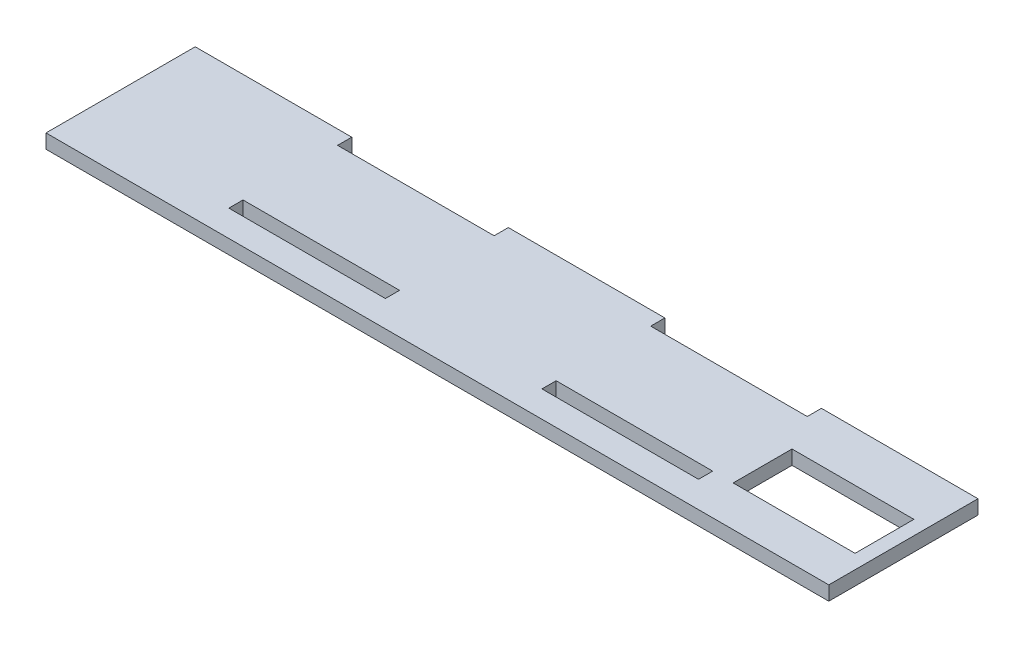
from build123d import *

# Parameters (mm, degrees)
SKETCH1_W           = 29.8
SKETCH1_H           = 2.7
SKETCH1_W_2         = 23.2
SKETCH1_H_2         = 11.2
BOSS_EXTRUDE1_DEPTH = 2.7


with BuildPart() as part:
    # Sketch1 → Boss-Extrude1 (new body)
    with BuildSketch(Plane(origin=(0, 0, 0), x_dir=(1, 0, 0), z_dir=(0, 1, 0))):
        Polygon((-74.5, -14.2), (74.5, -14.2), (74.5, 14.2), (44.7, 14.2), (44.7, 11.5), (14.9, 11.5), (14.9, 14.2), (-14.9, 14.2), (-14.9, 11.5), (-44.7, 11.5), (-44.7, 14.2), (-74.5, 14.2), align=None)
        with Locations((-29.8, -7.85)):
            Rectangle(SKETCH1_W, SKETCH1_H, mode=Mode.SUBTRACT)
        with Locations((29.8, -7.85)):
            Rectangle(SKETCH1_W, SKETCH1_H, mode=Mode.SUBTRACT)
        with Locations((60.2, -0.9)):
            Rectangle(SKETCH1_W_2, SKETCH1_H_2, mode=Mode.SUBTRACT)
    extrude(amount=BOSS_EXTRUDE1_DEPTH)


solid = part.part
